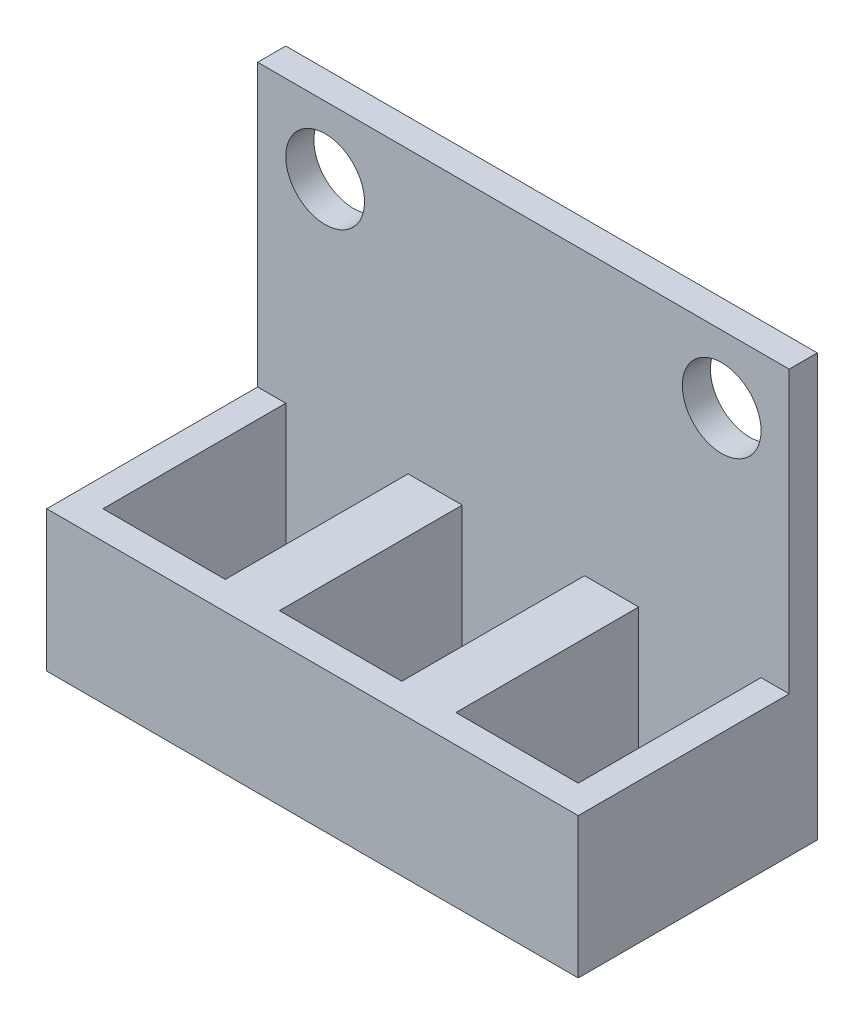
from build123d import *

# Parameters (mm, degrees)
SKETCH1_W           = 18.9
SKETCH1_H           = 8.5
SKETCH1_W_2         = 4.35
SKETCH1_H_2         = 6.5
BOSS_EXTRUDE1_DEPTH = 5
SKETCH2_W           = 18.9
SKETCH2_H           = 1
BOSS_EXTRUDE2_DEPTH = 10
SKETCH3_R           = 1.4
CUT_EXTRUDE1_DEPTH  = 2


with BuildPart() as part:
    # Sketch1 → Boss-Extrude1 (new body)
    with BuildSketch(Plane(origin=(0, 0, 0), x_dir=(1, 0, 0), z_dir=(0, 1, 0))):
        Rectangle(SKETCH1_W, SKETCH1_H)
        with Locations((-6.275, 0)):
            Rectangle(SKETCH1_W_2, SKETCH1_H_2, mode=Mode.SUBTRACT)
        Rectangle(SKETCH1_W_2, SKETCH1_H_2, mode=Mode.SUBTRACT)
        with Locations((6.275, 0)):
            Rectangle(SKETCH1_W_2, SKETCH1_H_2, mode=Mode.SUBTRACT)
    extrude(amount=BOSS_EXTRUDE1_DEPTH)

    # Sketch2 → Boss-Extrude2 (add)
    with BuildSketch(Plane(origin=(0, 5, 0), x_dir=(1, 0, 0), z_dir=(0, 1, 0))):
        with Locations((0, 3.75)):
            Rectangle(SKETCH2_W, SKETCH2_H)
    extrude(amount=BOSS_EXTRUDE2_DEPTH)

    # Sketch3 → Cut-Extrude1 (cut, through all)
    with BuildSketch(Plane.XY.offset(-3.25)):
        with Locations((7.05, 12.6)):
            Circle(SKETCH3_R)
        with Locations((-7.05, 12.6)):
            Circle(SKETCH3_R)
    extrude(amount=-CUT_EXTRUDE1_DEPTH, mode=Mode.SUBTRACT)


solid = part.part
